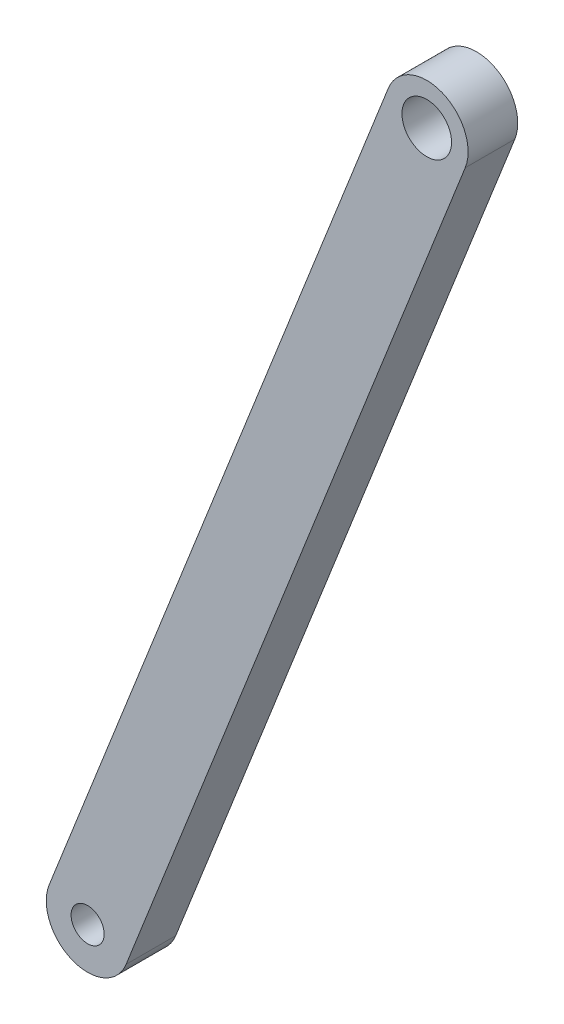
from build123d import *

# Parameters (mm, degrees)
AUFSATZ_LINEAR_AUSTRAGEN1_DEPTH      = 3
AUFSATZ_LINEAR_AUSTRAGEN1_DEPTH_BACK = 3
SKIZZE3_R                            = 3
SKIZZE3_R_2                          = 2


with BuildPart() as part:
    # Skizze3 → Aufsatz-Linear austragen1 (new, two sides: drawn at the far end of the back side and taken through both)
    with BuildSketch(Plane.XY.offset(-AUFSATZ_LINEAR_AUSTRAGEN1_DEPTH_BACK)):
        with BuildLine():
            Line((24.349022765, 567.935323067), (65.349022765, 671.835323067))
            ThreePointArc((65.349022765, 671.835323067), (71.835323067, 674.650977235), (74.650977235, 668.164676933))
            Line((74.650977235, 668.164676933), (33.650977235, 564.264676933))
            ThreePointArc((33.650977235, 564.264676933), (27.164676933, 561.449022765), (24.349022765, 567.935323067))
        make_face()
        with Locations((70, 670)):
            Circle(SKIZZE3_R, mode=Mode.SUBTRACT)
        with Locations((29, 566.1)):
            Circle(SKIZZE3_R_2, mode=Mode.SUBTRACT)
    extrude(amount=AUFSATZ_LINEAR_AUSTRAGEN1_DEPTH + AUFSATZ_LINEAR_AUSTRAGEN1_DEPTH_BACK)


solid = part.part
